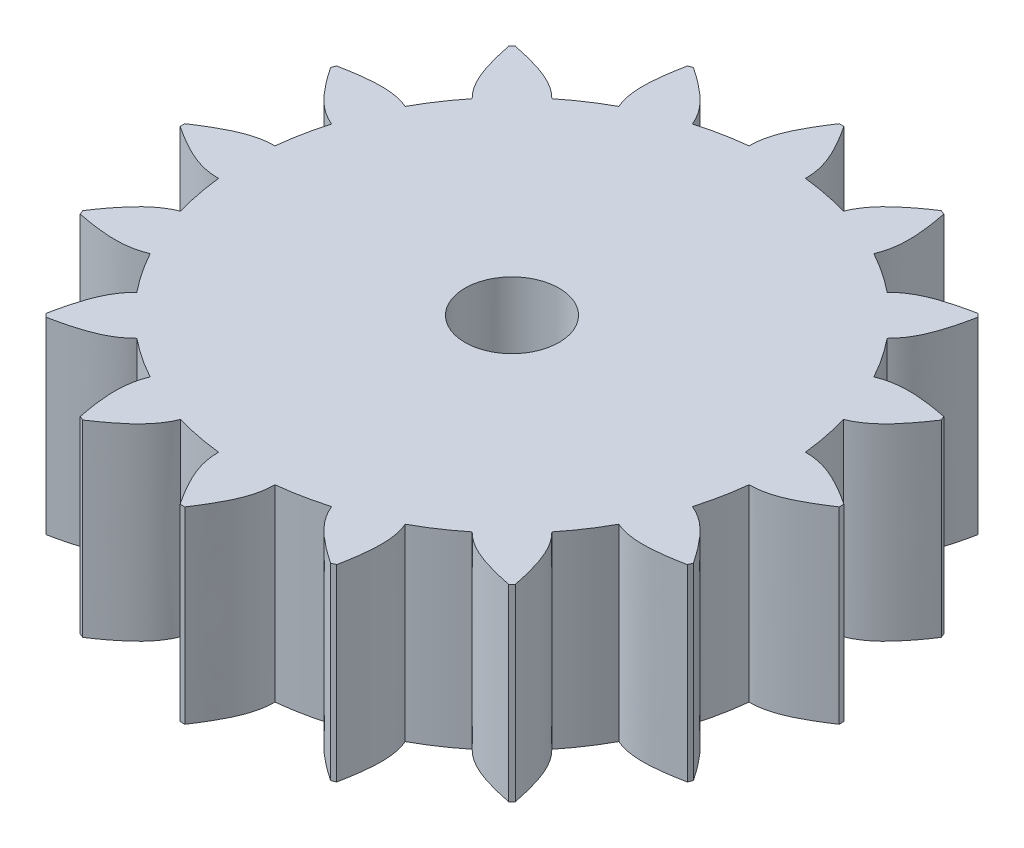
from build123d import *

# Parameters (mm, degrees)
BOSS_EXTRUDE1_DEPTH = 7.62
CIRPATTERN1_COUNT   = 16
SKETCH2_R           = 1.905
CUT_EXTRUDE1_DEPTH  = 8.6200001
SKETCH4_R           = 3.175
CUT_EXTRUDE2_DEPTH  = 3.81


with BuildPart() as part:
    # Sketch1 → Boss-Extrude1 (new body)
    with BuildSketch(Plane(origin=(0, 0, 0), x_dir=(1, 0, 0), z_dir=(0, 1, 0))):
        with BuildLine():
            add(Edge.make_bspline(
                [(1.139719329, 10.734666499), (1.147399116, 11.22537279), (0.871214241, 12.119041795), (0.344554873, 12.955131401), (0.094484742, 13.334665261)],
                knots=[0.007821969, 0.007821969, 0.007821969, 0.007821969, 0.5, 0.928051836, 0.928051836, 0.928051836, 0.928051836], degree=3))
            ThreePointArc((0.094484742, 13.334665261), (0, 13.335), (-0.094484742, 13.334665261))
            add(Edge.make_bspline(
                [(-1.139719329, 10.734666499), (-1.147399116, 11.22537279), (-0.871214241, 12.119041795), (-0.344554873, 12.955131401), (-0.094484742, 13.334665261)],
                knots=[0.007821969, 0.007821969, 0.007821969, 0.007821969, 0.5, 0.928051836, 0.928051836, 0.928051836, 0.928051836], degree=3))
            ThreePointArc((-1.139719329, 10.734666499), (0, -10.795), (1.139719329, 10.734666499))
        make_face()
    boss_extrude1 = extrude(amount=BOSS_EXTRUDE1_DEPTH)

    # CirPattern1: Boss-Extrude1 ×16 about axis
    cirpattern1_axis = Axis((0, 7.62, 0), (0, 1, 0))
    for i in range(1, CIRPATTERN1_COUNT):
        add(boss_extrude1.rotate(cirpattern1_axis, i * 360 / CIRPATTERN1_COUNT))

    # Sketch2 → Cut-Extrude1 (cut, through all)
    with BuildSketch(Plane(origin=(0, 7.62, 0), x_dir=(1, 0, 0), z_dir=(0, 1, 0))):
        Circle(SKETCH2_R)
    extrude(amount=-CUT_EXTRUDE1_DEPTH, mode=Mode.SUBTRACT)

    # Sketch4 → Cut-Extrude2 (cut)
    with BuildSketch(Plane.XZ):
        Circle(SKETCH4_R)
    extrude(amount=-CUT_EXTRUDE2_DEPTH, mode=Mode.SUBTRACT)


solid = part.part
